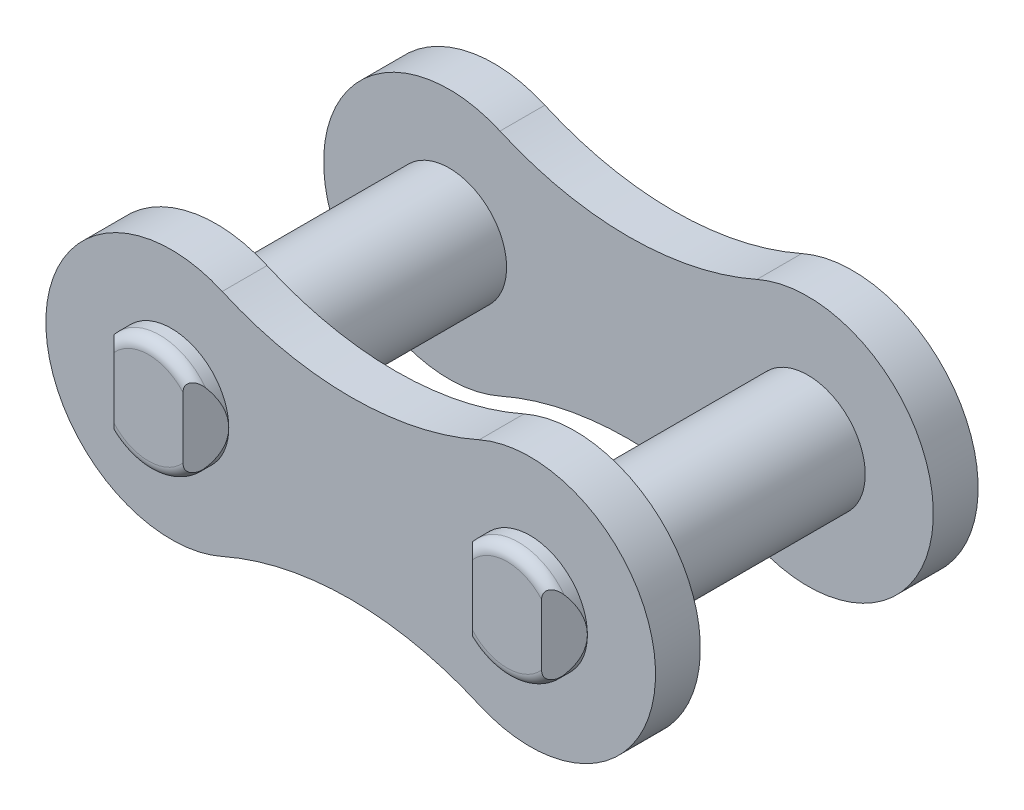
from build123d import *

# Parameters (mm, degrees)
BOSS_EXTRUDE2_START     = 5.1562
SKETCH2_R               = 2.54
BOSS_EXTRUDE2_DEPTH     = 1.984375
CUT_EXTRUDE1_DEPTH      = 6.55625
CUT_EXTRUDE1_DEPTH_BACK = 6.55625


with BuildPart() as part:
    # Sketch1 → Revolve1 (revolve)
    with BuildSketch(Plane(origin=(0, 0, 0), x_dir=(1, 0, 0), z_dir=(0, 1, 0))):
        with BuildLine():
            Line((0, -8.1534), (-2.04, -8.1534))
            ThreePointArc((-2.04, -8.1534), (-2.393553391, -8.006953391), (-2.54, -7.6534))
            Line((-2.54, -7.6534), (-2.54, 7.6534))
            ThreePointArc((-2.54, 7.6534), (-2.393553391, 8.006953391), (-2.04, 8.1534))
            Line((-2.04, 8.1534), (0, 8.1534))
            Line((0, 8.1534), (0, -8.1534))
        make_face()
    revolve(axis=Axis((0, 0, 8.1534), (0, 0, -1)))

    # Sketch6 → Cut-Extrude1 (cut, two sides)
    with BuildSketch(Plane(origin=(0, 0, 0), x_dir=(1, 0, 0), z_dir=(0, 1, 0))) as cut_extrude1_sk:
        Polygon((1.527175, -8.1534), (2.54, -7.140575), (2.54, -9.1534), (-2.54, -9.1534), (-2.54, -7.140575), (-1.527175, -8.1534), align=None)
        Polygon((-2.54, 9.1534), (2.54, 9.1534), (2.54, 7.140575), (1.527175, 8.1534), (-1.527175, 8.1534), (-2.54, 7.140575), align=None)
    extrude(amount=CUT_EXTRUDE1_DEPTH, mode=Mode.SUBTRACT)
    extrude(cut_extrude1_sk.sketch, amount=-CUT_EXTRUDE1_DEPTH_BACK, mode=Mode.SUBTRACT)


with BuildPart() as body_2:
    # Sketch2 → Boss-Extrude2 (new body)
    with BuildSketch(Plane.XY.offset(BOSS_EXTRUDE2_START)):
        with BuildLine():
            ThreePointArc((2.250669692, 5.08), (-5.55625, 0), (2.250669692, -5.08))
            ThreePointArc((2.250669692, -5.08), (7.9375, -3.876645752), (13.624330308, -5.08))
            ThreePointArc((13.624330308, -5.08), (21.43125, 0), (13.624330308, 5.08))
            ThreePointArc((13.624330308, 5.08), (7.9375, 3.876645752), (2.250669692, 5.08))
        make_face()
        Circle(SKETCH2_R, mode=Mode.SUBTRACT)
        with Locations((15.875, 0)):
            Circle(SKETCH2_R, mode=Mode.SUBTRACT)
    extrude(amount=BOSS_EXTRUDE2_DEPTH)


with BuildPart() as body_3:
    # Mirror5: mirrored copy
    add(part.part.mirror(Plane(origin=(7.9375, 0, 0), x_dir=(0, 0, 1), z_dir=(1, 0, 0))))


with BuildPart() as body_4:
    # Mirror6: mirrored copy
    add(body_2.part.mirror(Plane.XY))


solid = Compound([part.part, body_2.part, body_3.part, body_4.part])
